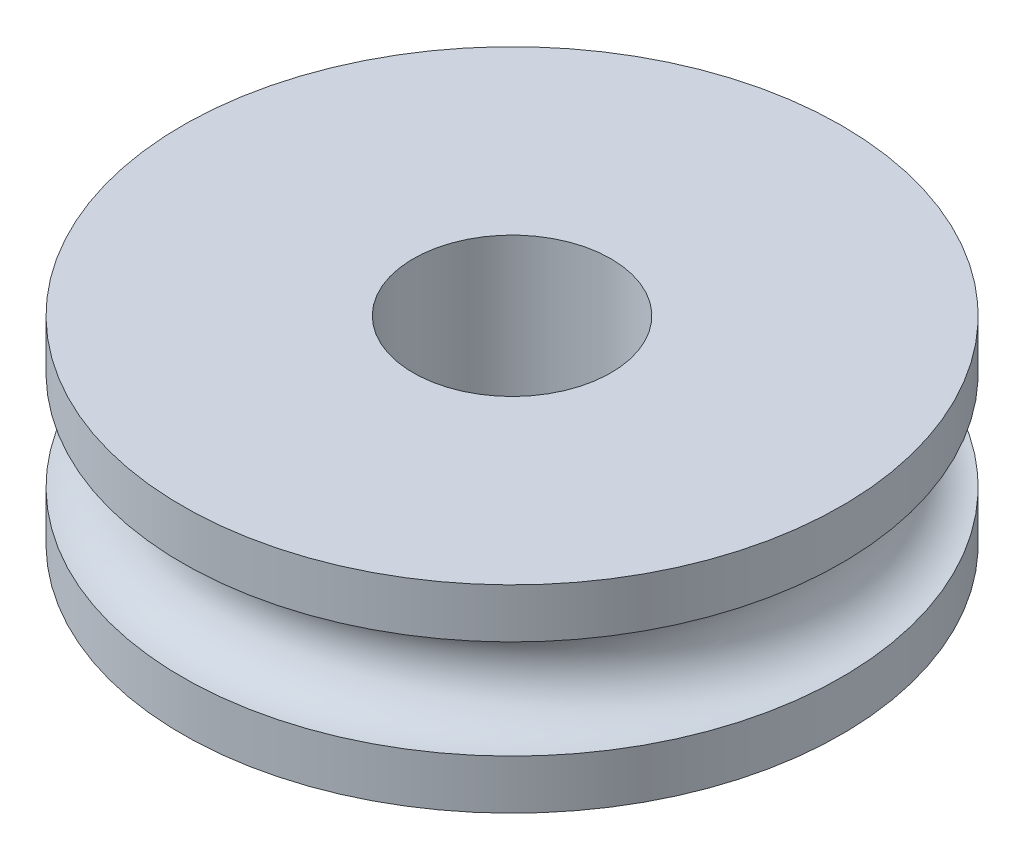
from build123d import *


with BuildPart() as part:
    # Sketch1 → Revolve1 (revolve)
    with BuildSketch(Plane(origin=(0, 0, 0), x_dir=(0, 0, -1), z_dir=(1, 0, 0))):
        with BuildLine():
            Line((-1.5, 1.5), (-5, 1.5))
            Line((-5, 1.5), (-5, 0.75))
            ThreePointArc((-5, 0.75), (-4.25, 0), (-5, -0.75))
            Line((-5, -0.75), (-5, -1.5))
            Line((-5, -1.5), (-1.5, -1.5))
            Line((-1.5, -1.5), (-1.5, 1.5))
        make_face()
    revolve(axis=Axis((0, 0, 0), (0, 1, 0)))


solid = part.part
